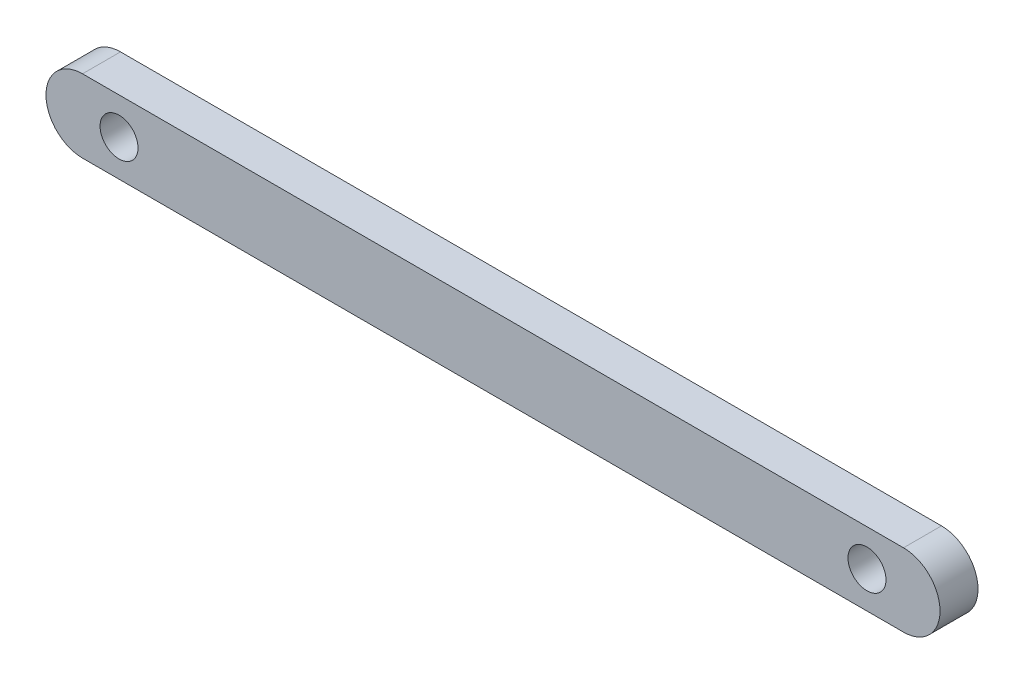
from build123d import *

# Parameters (mm, degrees)
SKETCH1_R           = 1.651
BOSS_EXTRUDE1_DEPTH = 3.302


with BuildPart() as part:
    # Sketch1 → Boss-Extrude1 (new body)
    with BuildSketch(Plane.XY):
        with BuildLine():
            Line((0, 3.175), (71.374, 3.175))
            ThreePointArc((71.374, 3.175), (74.549, 0), (71.374, -3.175))
            Line((71.374, -3.175), (0, -3.175))
            ThreePointArc((0, -3.175), (-3.175, 0), (0, 3.175))
        make_face()
        with Locations((3.175, 0)):
            Circle(SKETCH1_R, mode=Mode.SUBTRACT)
        with Locations((68.199, 0)):
            Circle(SKETCH1_R, mode=Mode.SUBTRACT)
    extrude(amount=BOSS_EXTRUDE1_DEPTH)


solid = part.part
